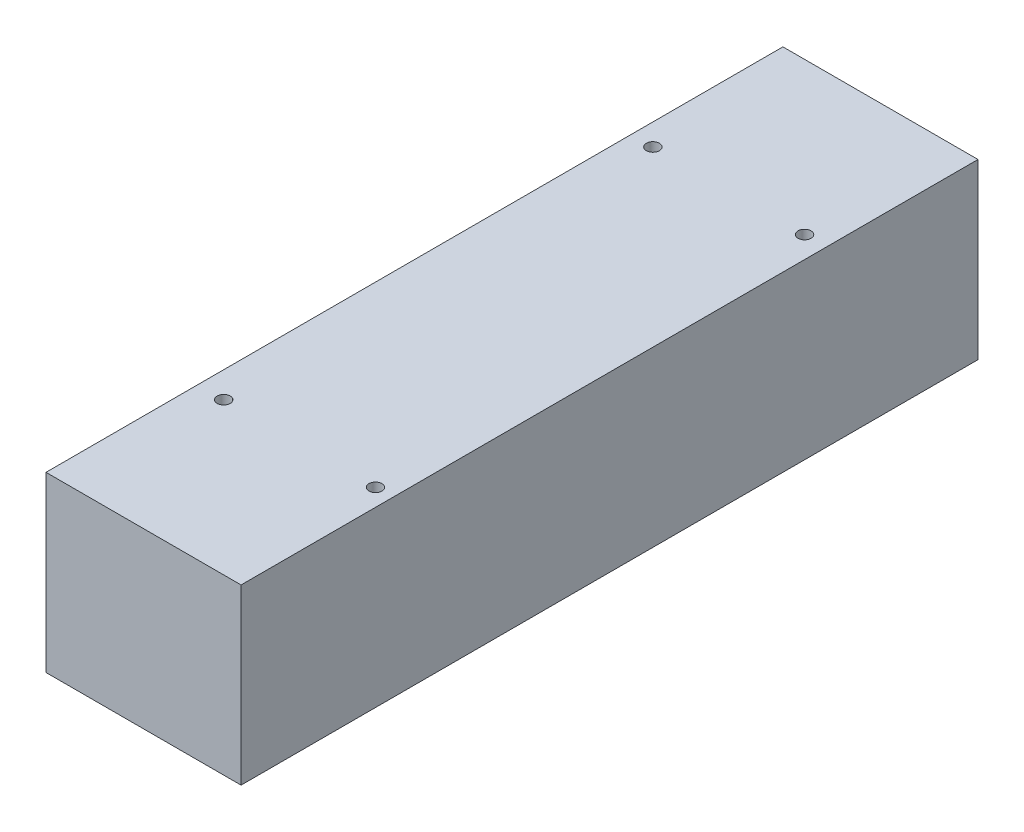
from build123d import *

# Parameters (mm, degrees)
ESQUISSE1_W             = 45
ESQUISSE1_H             = 40
BOSS_EXTRU_1_DEPTH      = 170
ESQUISSE2_R             = 1.5
ENL_V_MAT_EXTRU_1_DEPTH = 6


with BuildPart() as part:
    # Esquisse1 → Boss.-Extru.1 (new body)
    with BuildSketch(Plane.XY):
        with Locations((-13.615564763, 2.403846154)):
            Rectangle(ESQUISSE1_W, ESQUISSE1_H)
    extrude(amount=BOSS_EXTRU_1_DEPTH)

    # Esquisse2 → Enlèv. mat.-Extru.1 (cut)
    with BuildSketch(Plane(origin=(0, 22.403846154, 0), x_dir=(1, 0, 0), z_dir=(0, 1, 0))):
        with Locations((-31.115564763, -35.005000125)):
            Circle(ESQUISSE2_R)
        with Locations((3.884435237, -35.005000125)):
            Circle(ESQUISSE2_R)
        with Locations((-30.115564763, -135)):
            Circle(ESQUISSE2_R)
        with Locations((4.884435237, -135)):
            Circle(ESQUISSE2_R)
    extrude(amount=-ENL_V_MAT_EXTRU_1_DEPTH, mode=Mode.SUBTRACT)


solid = part.part
